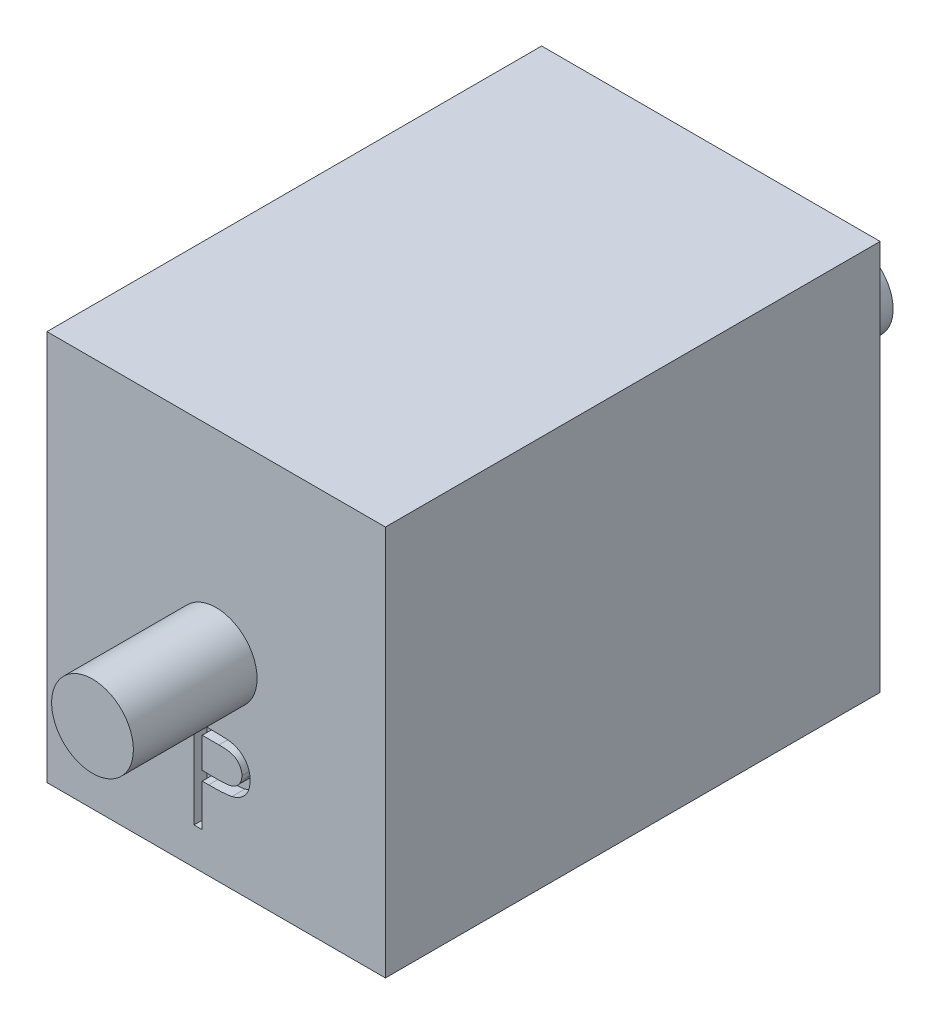
from build123d import *

# Parameters (mm, degrees)
SKETCH1_W           = 13
SKETCH1_H           = 15
BOSS_EXTRUDE1_DEPTH = 19
SKETCH2_R           = 1.57
BOSS_EXTRUDE2_DEPTH = 4.75
SKETCH3_R           = 1.5
BOSS_EXTRUDE3_DEPTH = 5.5
CUT_EXTRUDE1_DEPTH  = 0.5
CUT_EXTRUDE2_DEPTH  = 0.5


with BuildPart() as part:
    # Sketch1 → Boss-Extrude1 (new body)
    with BuildSketch(Plane.XY):
        Rectangle(SKETCH1_W, SKETCH1_H)
    extrude(amount=BOSS_EXTRUDE1_DEPTH)

    # Sketch2 → Boss-Extrude2 (add)
    with BuildSketch(Plane.XY.offset(19)):
        Circle(SKETCH2_R)
    extrude(amount=BOSS_EXTRUDE2_DEPTH)

    # Sketch3 → Boss-Extrude3 (add)
    with BuildSketch(Plane(origin=(0, 0, 0), x_dir=(-1, 0, 0), z_dir=(0, 0, -1))):
        Circle(SKETCH3_R)
    extrude(amount=BOSS_EXTRUDE3_DEPTH)

    # Sketch4 → Cut-Extrude1 (cut)
    with BuildSketch(Plane(origin=(0, 0, 0), x_dir=(-1, 0, 0), z_dir=(0, 0, -1))):
        Polygon((-2.028652102, -5.782501305), (-1.56661284, -2.282501305), (-1.521741045, -2.282501305), (-0.076729025, -5.154296177), (1.364076263, -2.282501305), (1.408948058, -2.282501305), (1.875194051, -5.782501305), (1.561091487, -5.782501305), (1.224553026, -3.266175183), (-0.038167327, -5.782501305), (-0.10968175, -5.782501305), (-1.378011077, -3.258462844), (-1.712446173, -5.782501305), align=None)
    extrude(amount=-CUT_EXTRUDE1_DEPTH, mode=Mode.SUBTRACT)

    # Sketch5 → Cut-Extrude2 (cut)
    with BuildSketch(Plane.XY.offset(19)):
        with BuildLine():
            Line((-0.851399992, -2.584854315), (-0.165001755, -2.584854315))
            add(Edge.make_bspline(
                [(-0.165001755, -2.584854315), (-0.117790848, -2.584906211), (-0.027332656, -2.585005646), (0.1023824, -2.588020392), (0.220192132, -2.592047084), (0.325842513, -2.597628978), (0.419658611, -2.604225568), (0.50121591, -2.613477607), (0.571155467, -2.623137903), (0.613061916, -2.632959309), (0.632173726, -2.637438449)],
                knots=[0, 0, 0, 0, 0.000141628, 0.000271366, 0.00038923, 0.000495248, 0.00058876, 0.000671296, 0.000741499, 0.00080036, 0.00080036, 0.00080036, 0.00080036], degree=3))
            add(Edge.make_bspline(
                [(0.632173726, -2.637438449), (0.65636726, -2.644060399), (0.704184237, -2.657148261), (0.77308528, -2.683361984), (0.838639126, -2.71444415), (0.901070684, -2.749868089), (0.959612767, -2.791153654), (1.015138808, -2.836627271), (1.067158788, -2.88733884), (1.11538018, -2.94271958), (1.159664978, -3.00183979), (1.197794661, -3.06558202), (1.229721888, -3.132873323), (1.257105159, -3.203666894), (1.276813614, -3.278557218), (1.291660513, -3.35702393), (1.301084141, -3.43905862), (1.301986703, -3.495118488), (1.302446162, -3.523656398)],
                knots=[0, 0, 0, 0, 7.5216e-05, 0.00014866, 0.000220794, 0.000292713, 0.000363707, 0.000435434, 0.000507823, 0.000581364, 0.000655543, 0.000729131, 0.000803767, 0.000878771, 0.000956497, 0.001035702, 0.001118238, 0.001203821, 0.001203821, 0.001203821, 0.001203821], degree=3))
            add(Edge.make_bspline(
                [(1.302446162, -3.523656398), (1.302024737, -3.552434175), (1.301200191, -3.608739839), (1.291303906, -3.691112627), (1.277973714, -3.769831017), (1.257476662, -3.844720468), (1.230630989, -3.915336238), (1.199138936, -3.98275747), (1.161155406, -4.045837142), (1.117510576, -4.10480426), (1.068958982, -4.159714172), (1.015706044, -4.210168966), (0.957966751, -4.255873305), (0.895924603, -4.296929648), (0.828974754, -4.332385928), (0.758132601, -4.364143233), (0.682782384, -4.390814293), (0.63063987, -4.404844355), (0.604128854, -4.411977712)],
                knots=[0, 0, 0, 0, 8.6284e-05, 0.00016882, 0.000248587, 0.000325638, 0.000401297, 0.000474998, 0.000548586, 0.000621785, 0.0006948, 0.0007682, 0.000841564, 0.000915458, 0.000991056, 0.00106858, 0.00114819, 0.001230532, 0.001230532, 0.001230532, 0.001230532], degree=3))
            add(Edge.make_bspline(
                [(0.604128854, -4.411977712), (0.58220152, -4.416640693), (0.534146493, -4.426859887), (0.455003771, -4.438268344), (0.362858385, -4.448005945), (0.257836105, -4.455307082), (0.1400312, -4.461557451), (0.009379943, -4.466525545), (-0.134374134, -4.469255399), (-0.234645379, -4.469396191), (-0.286996947, -4.469469699)],
                knots=[0, 0, 0, 0, 6.7238e-05, 0.000147357, 0.000239727, 0.000345177, 0.000463135, 0.000593636, 0.000737393, 0.000894446, 0.000894446, 0.000894446, 0.000894446], degree=3))
            Line((-0.286996947, -4.469469699), (-0.537297428, -4.469469699))
            Line((-0.537297428, -4.469469699), (-0.537297428, -6.084854315))
            Line((-0.537297428, -6.084854315), (-0.851399992, -6.084854315))
            Line((-0.851399992, -6.084854315), (-0.851399992, -2.584854315))
        make_face()
        with BuildLine():
            Line((-0.537297428, -2.943828674), (-0.537297428, -4.11049534))
            Line((-0.537297428, -4.11049534), (0.075483021, -4.11820768))
            add(Edge.make_bspline(
                [(0.075483021, -4.11820768), (0.105402947, -4.118223144), (0.163162747, -4.118252996), (0.24659897, -4.114267772), (0.324008257, -4.10966724), (0.395152833, -4.102931316), (0.460064767, -4.093410059), (0.518852296, -4.083798321), (0.571059579, -4.069892958), (0.632158781, -4.051169889), (0.700242128, -4.019237273), (0.774309677, -3.972887383), (0.837080263, -3.913806675), (0.89139856, -3.847378844), (0.934504438, -3.773479714), (0.96606043, -3.694410778), (0.984601587, -3.610982928), (0.987087781, -3.553894789), (0.988343598, -3.525058642)],
                knots=[0, 0, 0, 0, 8.9746e-05, 0.000173253, 0.000250533, 0.00032239, 0.000387534, 0.00044736, 0.000500926, 0.000549486, 0.000638903, 0.000725641, 0.000810488, 0.000896226, 0.000982324, 0.00106604, 0.001150757, 0.001237226, 0.001237226, 0.001237226, 0.001237226], degree=3))
            add(Edge.make_bspline(
                [(0.988343598, -3.525058642), (0.987080951, -3.496920128), (0.984570966, -3.440984246), (0.965915103, -3.359005485), (0.934565789, -3.280769781), (0.891109195, -3.207796696), (0.838368065, -3.141607892), (0.777068722, -3.084110765), (0.707355461, -3.037889062), (0.642507229, -3.00805578), (0.584906043, -2.989840505), (0.534874084, -2.977095664), (0.478383409, -2.966920058), (0.41541563, -2.958680555), (0.346458796, -2.951627094), (0.270920481, -2.946841117), (0.189086838, -2.944039661), (0.132276267, -2.943900705), (0.102826771, -2.943828674)],
                knots=[0, 0, 0, 0, 8.4371e-05, 0.000167719, 0.000250783, 0.000336277, 0.000421575, 0.000503926, 0.000587348, 0.000671427, 0.000717102, 0.000768457, 0.000826213, 0.000889178, 0.000958942, 0.001034123, 0.001116202, 0.001204546, 0.001204546, 0.001204546, 0.001204546], degree=3))
            Line((0.102826771, -2.943828674), (-0.537297428, -2.943828674))
        make_face(mode=Mode.SUBTRACT)
    extrude(amount=-CUT_EXTRUDE2_DEPTH, mode=Mode.SUBTRACT)


solid = part.part
